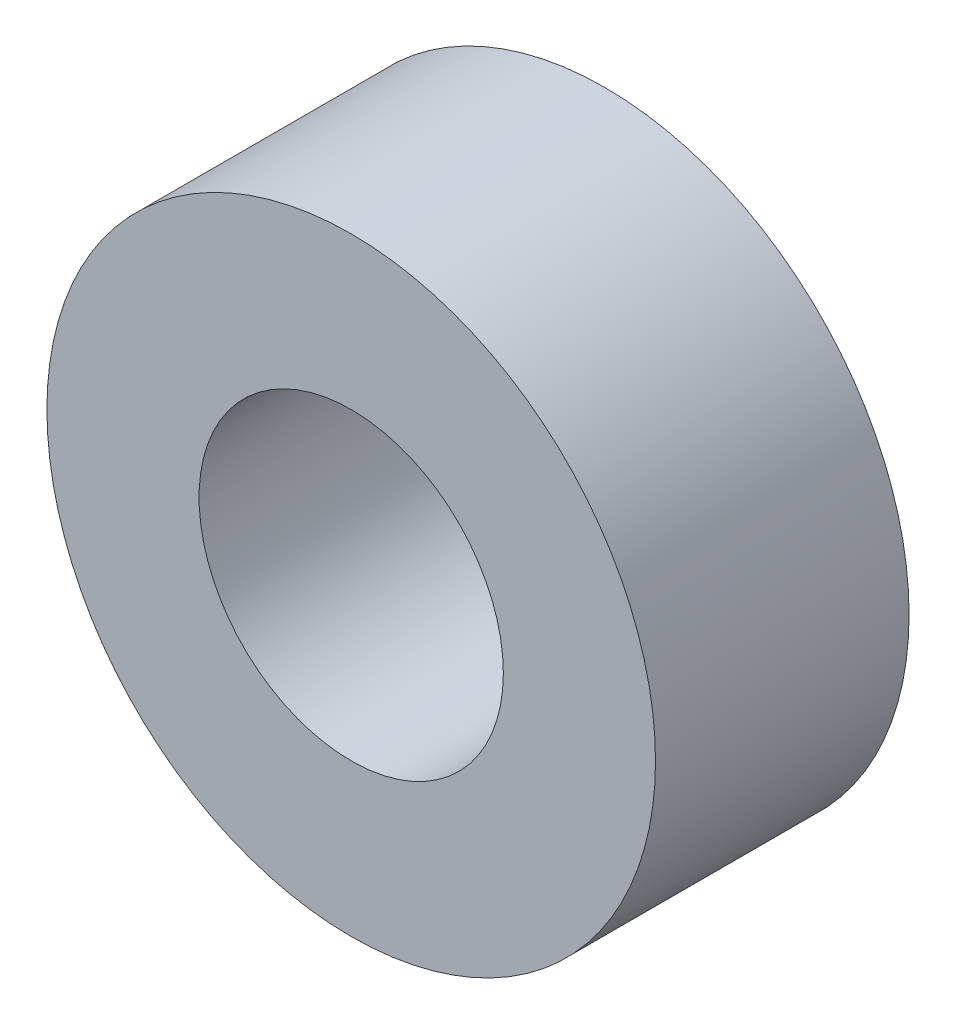
from build123d import *

# Parameters (mm, degrees)
SKETCH_1_R      = 3
SKETCH_1_R_2    = 1.5
EXTRUDE_1_DEPTH = 2.5


with BuildPart() as part:
    # 草图1 → 凸台-拉伸1 (new body)
    with BuildSketch(Plane.XY):
        Circle(SKETCH_1_R)
        Circle(SKETCH_1_R_2, mode=Mode.SUBTRACT)
    extrude(amount=EXTRUDE_1_DEPTH)


solid = part.part
